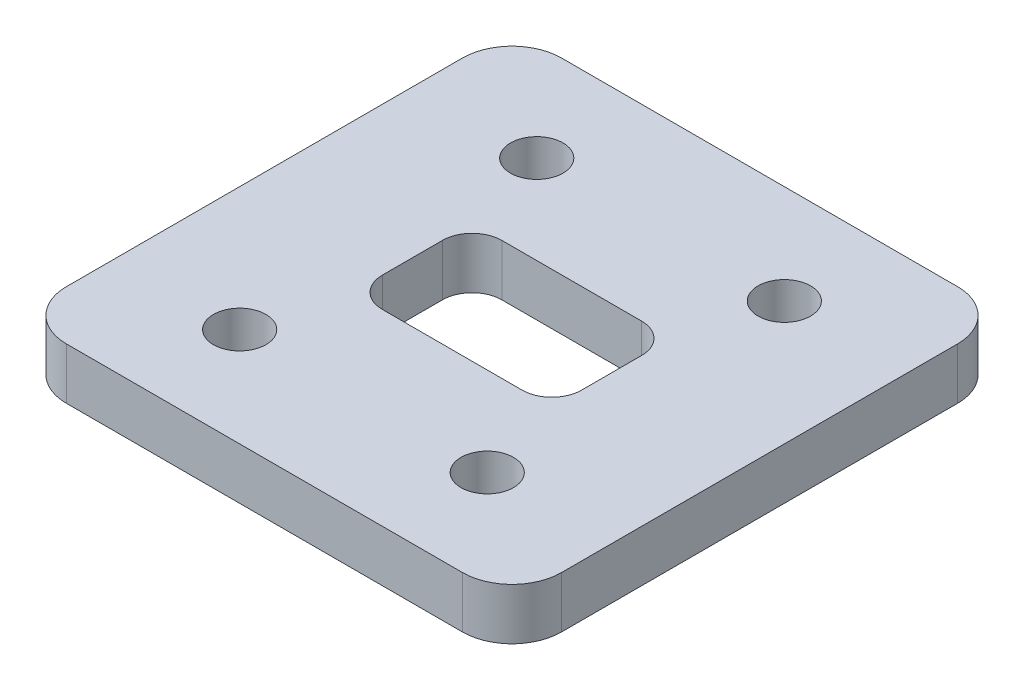
from build123d import *

# Parameters (mm, degrees)
CROQUIS1_R              = 2.65
SALIENTE_EXTRUIR2_DEPTH = 8
CORTAR_EXTRUIR1_START   = 8
CROQUIS1_4_R            = 2.65
CORTAR_EXTRUIR1_DEPTH   = 2.8


with BuildPart() as part:
    # Croquis1 → Saliente-Extruir2 (new body)
    with BuildSketch(Plane(origin=(0, 0, 0), x_dir=(1, 0, 0), z_dir=(0, 1, 0))):
        with BuildLine():
            Line((-20, -25), (20, -25))
            ThreePointArc((20, -25), (23.535533906, -23.535533906), (25, -20))
            Line((25, -20), (25, 20))
            ThreePointArc((25, 20), (23.535533906, 23.535533906), (20, 25))
            Line((20, 25), (-20, 25))
            ThreePointArc((-20, 25), (-23.535533906, 23.535533906), (-25, 20))
            Line((-25, 20), (-25, -20))
            ThreePointArc((-25, -20), (-23.535533906, -23.535533906), (-20, -25))
        make_face()
        with Locations((-12.5, -15)):
            Circle(CROQUIS1_R, mode=Mode.SUBTRACT)
        with Locations((-12.5, 15)):
            Circle(CROQUIS1_R, mode=Mode.SUBTRACT)
        with Locations((12.5, -15)):
            Circle(CROQUIS1_R, mode=Mode.SUBTRACT)
        with Locations((12.5, 15)):
            Circle(CROQUIS1_R, mode=Mode.SUBTRACT)
        with BuildLine():
            Line((-7.060224725, -6.03567091), (7.060224725, -6.03567091))
            ThreePointArc((7.060224725, -6.03567091), (9.181545068, -5.156991253), (10.060224725, -3.03567091))
            Line((10.060224725, -3.03567091), (10.060224725, 3.03567091))
            ThreePointArc((10.060224725, 3.03567091), (9.181545068, 5.156991253), (7.060224725, 6.03567091))
            Line((7.060224725, 6.03567091), (-7.060224725, 6.03567091))
            ThreePointArc((-7.060224725, 6.03567091), (-9.181545068, 5.156991253), (-10.060224725, 3.03567091))
            Line((-10.060224725, 3.03567091), (-10.060224725, -3.03567091))
            ThreePointArc((-10.060224725, -3.03567091), (-9.181545068, -5.156991253), (-7.060224725, -6.03567091))
        make_face(mode=Mode.SUBTRACT)
    extrude(amount=SALIENTE_EXTRUIR2_DEPTH)

    # Croquis1_4 → Cortar-Extruir1 (cut)
    with BuildSketch(Plane(origin=(0, 0, 0), x_dir=(1, 0, 0), z_dir=(0, 1, 0)).offset(CORTAR_EXTRUIR1_START)):
        with BuildLine():
            Line((-20, -25), (20, -25))
            ThreePointArc((20, -25), (23.535533906, -23.535533906), (25, -20))
            Line((25, -20), (25, 20))
            ThreePointArc((25, 20), (23.535533906, 23.535533906), (20, 25))
            Line((20, 25), (-20, 25))
            ThreePointArc((-20, 25), (-23.535533906, 23.535533906), (-25, 20))
            Line((-25, 20), (-25, -20))
            ThreePointArc((-25, -20), (-23.535533906, -23.535533906), (-20, -25))
        make_face()
        with Locations((-12.5, -15)):
            Circle(CROQUIS1_4_R, mode=Mode.SUBTRACT)
        with Locations((-12.5, 15)):
            Circle(CROQUIS1_4_R, mode=Mode.SUBTRACT)
        with Locations((12.5, -15)):
            Circle(CROQUIS1_4_R, mode=Mode.SUBTRACT)
        with Locations((12.5, 15)):
            Circle(CROQUIS1_4_R, mode=Mode.SUBTRACT)
        with BuildLine():
            Line((-7.060224725, -6.03567091), (7.060224725, -6.03567091))
            ThreePointArc((7.060224725, -6.03567091), (9.181545068, -5.156991253), (10.060224725, -3.03567091))
            Line((10.060224725, -3.03567091), (10.060224725, 3.03567091))
            ThreePointArc((10.060224725, 3.03567091), (9.181545068, 5.156991253), (7.060224725, 6.03567091))
            Line((7.060224725, 6.03567091), (-7.060224725, 6.03567091))
            ThreePointArc((-7.060224725, 6.03567091), (-9.181545068, 5.156991253), (-10.060224725, 3.03567091))
            Line((-10.060224725, 3.03567091), (-10.060224725, -3.03567091))
            ThreePointArc((-10.060224725, -3.03567091), (-9.181545068, -5.156991253), (-7.060224725, -6.03567091))
        make_face(mode=Mode.SUBTRACT)
    extrude(amount=-CORTAR_EXTRUIR1_DEPTH, mode=Mode.SUBTRACT)


solid = part.part
